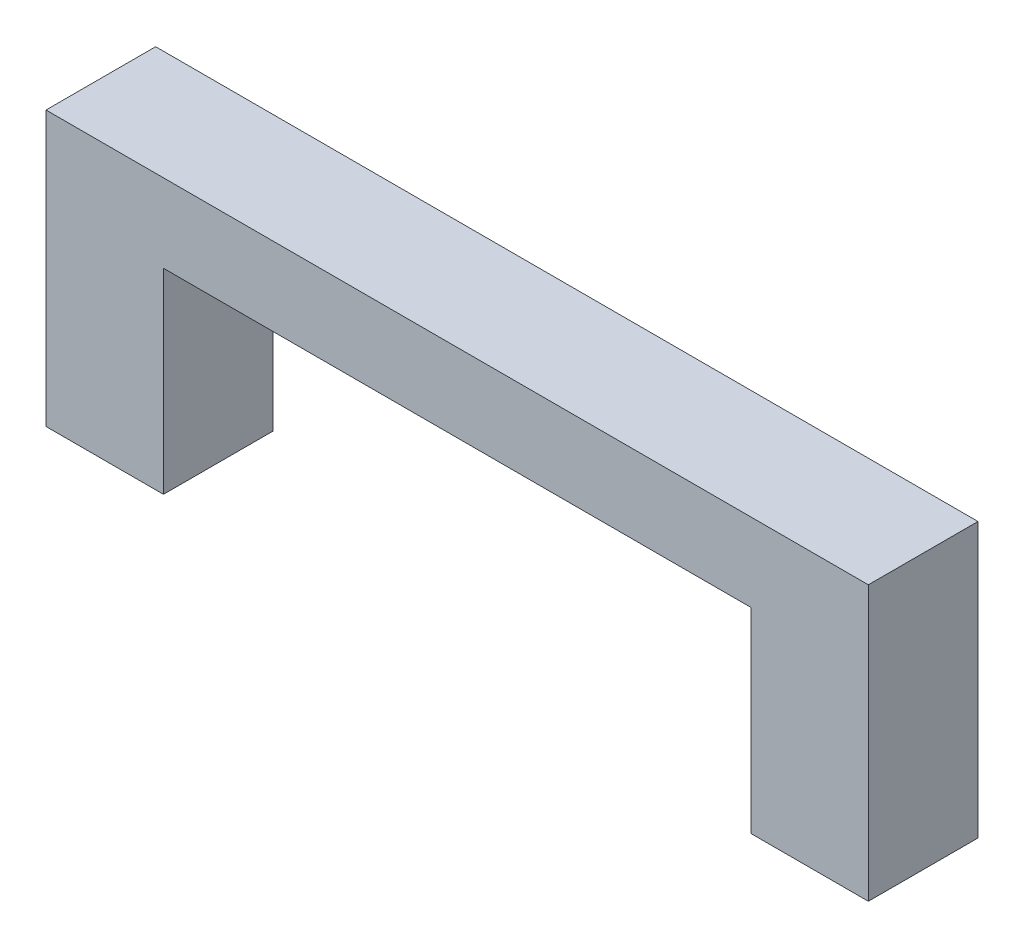
from build123d import *

# Parameters (mm, degrees)
BOSS_EXTRUDE1_DEPTH = 2.8
SKETCH2_W           = 2
SKETCH2_H           = 2
CUT_EXTRUDE1_DEPTH  = 2.2


with BuildPart() as part:
    # Sketch1 → Boss-Extrude1 (new body)
    with BuildSketch(Plane.XY):
        Polygon((0, 0), (0, 7), (21, 7), (21, 0), (18, 0), (18, 5), (3, 5), (3, 0), align=None)
    extrude(amount=BOSS_EXTRUDE1_DEPTH)

    # Sketch2 → Cut-Extrude1 (cut)
    with BuildSketch(Plane.XZ):
        with Locations((19.5, 1.4)):
            Rectangle(SKETCH2_W, SKETCH2_H)
        with Locations((1.5, 1.4)):
            Rectangle(SKETCH2_W, SKETCH2_H)
    extrude(amount=-CUT_EXTRUDE1_DEPTH, mode=Mode.SUBTRACT)


solid = part.part
